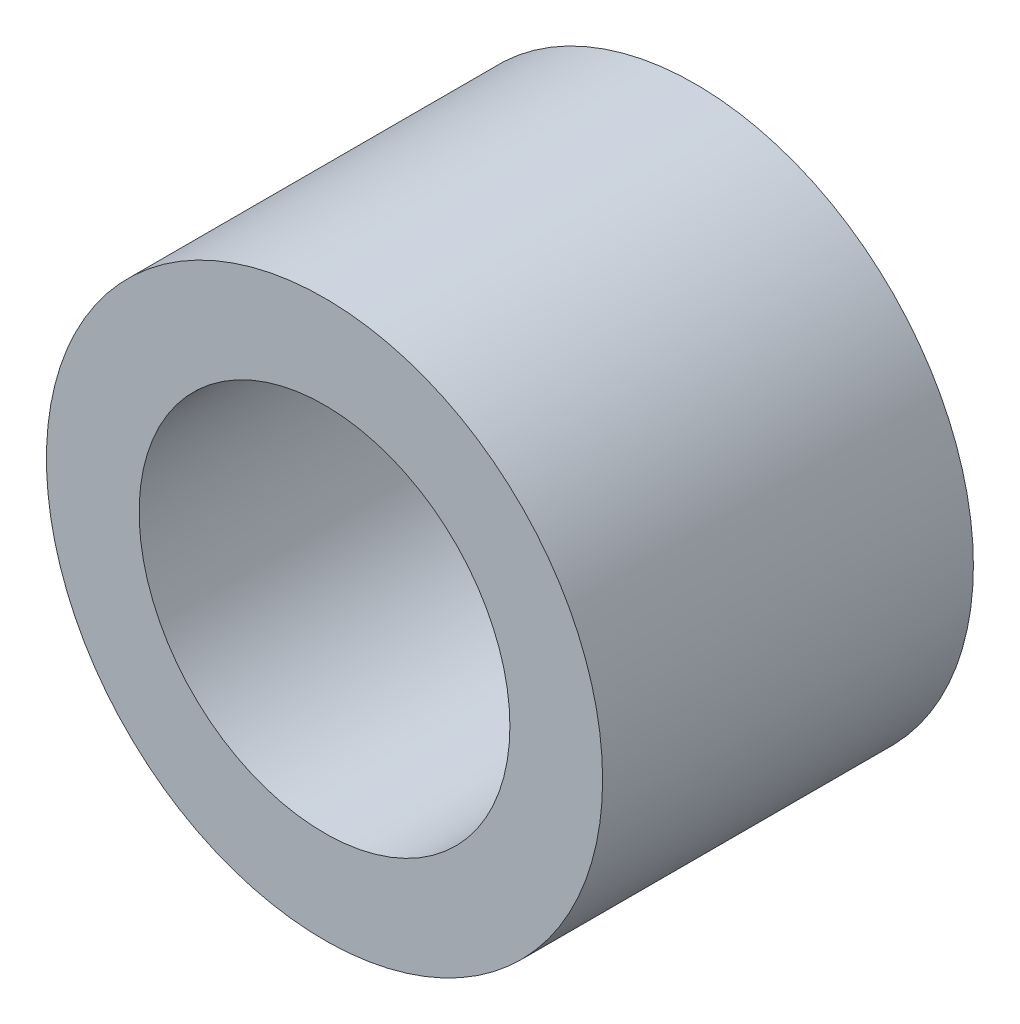
from build123d import *

# Parameters (mm, degrees)
SKETCH1_R      = 6
SKETCH1_R_2    = 4
EXTRUDE1_DEPTH = 4


with BuildPart() as part:
    # Sketch1 → Extrude1 (new body, symmetric)
    with BuildSketch(Plane.XY):
        Circle(SKETCH1_R)
        Circle(SKETCH1_R_2, mode=Mode.SUBTRACT)
    extrude(amount=EXTRUDE1_DEPTH, both=True)


solid = part.part
